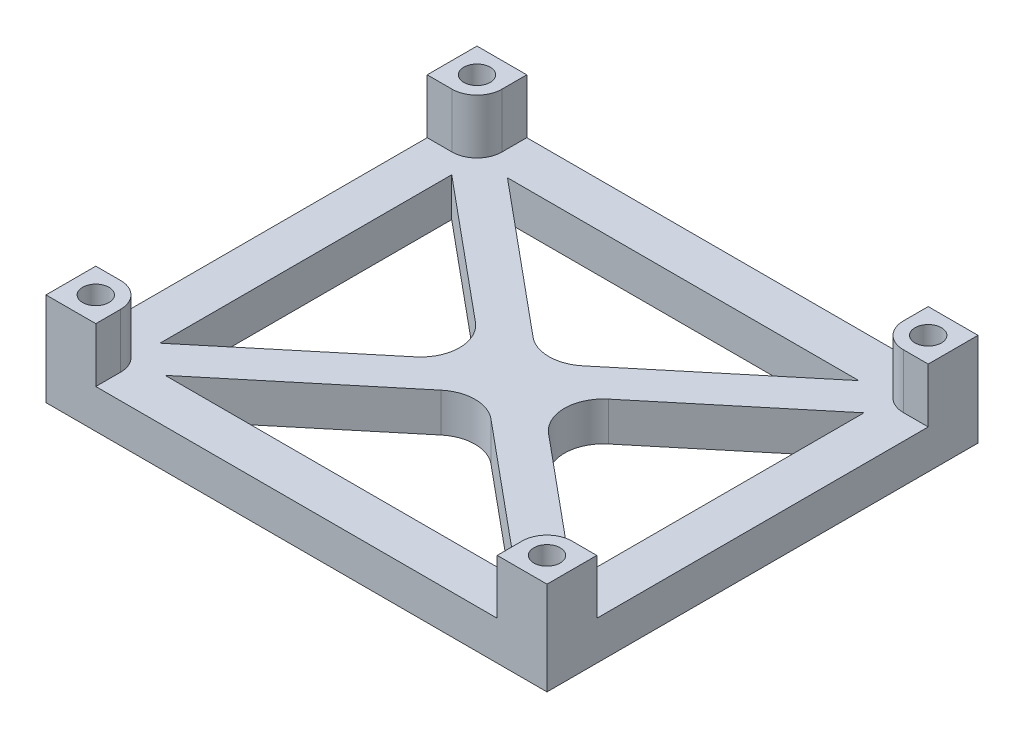
from build123d import *

# Parameters (mm, degrees)
SKETCH2_W           = 64.4
SKETCH2_H           = 55.4
SKETCH2_R           = 1.7
BOSS_EXTRUDE1_DEPTH = 5
FILLET1_R           = 5
SKETCH3_R           = 1.7
BOSS_EXTRUDE2_DEPTH = 7


with BuildPart() as part:
    # Sketch2 → Boss-Extrude1 (new body)
    with BuildSketch(Plane(origin=(0, 0, 0), x_dir=(1, 0, 0), z_dir=(0, 1, 0))):
        Rectangle(SKETCH2_W, SKETCH2_H)
        with Locations((-29, 24.5)):
            Circle(SKETCH2_R, mode=Mode.SUBTRACT)
        with Locations((29, 24.5)):
            Circle(SKETCH2_R, mode=Mode.SUBTRACT)
        with Locations((29, -24.5)):
            Circle(SKETCH2_R, mode=Mode.SUBTRACT)
        with Locations((-29, -24.5)):
            Circle(SKETCH2_R, mode=Mode.SUBTRACT)
        Polygon((-26.5, -18.750756585), (-26.5, 18.750756585), (-3.913861386, 0), align=None, mode=Mode.SUBTRACT)
        Polygon((26.5, -18.750756585), (26.5, 18.750756585), (3.913861386, 0), align=None, mode=Mode.SUBTRACT)
        Polygon((-22.586138614, -22), (0, -3.249243415), (22.586138614, -22), align=None, mode=Mode.SUBTRACT)
        Polygon((-22.586138614, 22), (0, 3.249243415), (22.586138614, 22), align=None, mode=Mode.SUBTRACT)
    extrude(amount=BOSS_EXTRUDE1_DEPTH)

    # Fillet1
    fillet1_edges = [part.edges().sort_by_distance(p)[0] for p in [
        (0, 2.5, 3.249243415),
        (3.913861386, 2.5, 0),
        (-3.913861386, 2.5, 0),
        (0, 2.5, -3.249243415),
    ]]
    fillet(fillet1_edges, radius=FILLET1_R)

    # Sketch3 → Boss-Extrude2 (add)
    with BuildSketch(Plane(origin=(0, 5, 0), x_dir=(1, 0, 0), z_dir=(0, 1, 0))):
        with BuildLine():
            Line((-32.2, -21.3), (-32.2, -27.7))
            Line((-32.2, -27.7), (-25.8, -27.7))
            Line((-25.8, -27.7), (-25.8, -24.5))
            ThreePointArc((-25.8, -24.5), (-26.7372583, -22.2372583), (-29, -21.3))
            Line((-29, -21.3), (-32.2, -21.3))
        make_face()
        with Locations((-29, -24.5)):
            Circle(SKETCH3_R, mode=Mode.SUBTRACT)
        with BuildLine():
            Line((-29, 21.3), (-32.2, 21.3))
            Line((-32.2, 21.3), (-32.2, 27.7))
            Line((-32.2, 27.7), (-25.8, 27.7))
            Line((-25.8, 27.7), (-25.8, 24.5))
            ThreePointArc((-25.8, 24.5), (-26.7372583, 22.2372583), (-29, 21.3))
        make_face()
        with Locations((-29, 24.5)):
            Circle(SKETCH3_R, mode=Mode.SUBTRACT)
        with BuildLine():
            Line((25.8, 24.5), (25.8, 27.7))
            Line((25.8, 27.7), (32.2, 27.7))
            Line((32.2, 27.7), (32.2, 21.3))
            Line((32.2, 21.3), (29, 21.3))
            ThreePointArc((29, 21.3), (26.7372583, 22.2372583), (25.8, 24.5))
        make_face()
        with Locations((29, 24.5)):
            Circle(SKETCH3_R, mode=Mode.SUBTRACT)
        with BuildLine():
            Line((25.8, -24.5), (25.8, -27.7))
            Line((25.8, -27.7), (32.2, -27.7))
            Line((32.2, -27.7), (32.2, -21.3))
            Line((32.2, -21.3), (29, -21.3))
            ThreePointArc((29, -21.3), (26.7372583, -22.2372583), (25.8, -24.5))
        make_face()
        with Locations((29, -24.5)):
            Circle(SKETCH3_R, mode=Mode.SUBTRACT)
    extrude(amount=BOSS_EXTRUDE2_DEPTH)


solid = part.part
